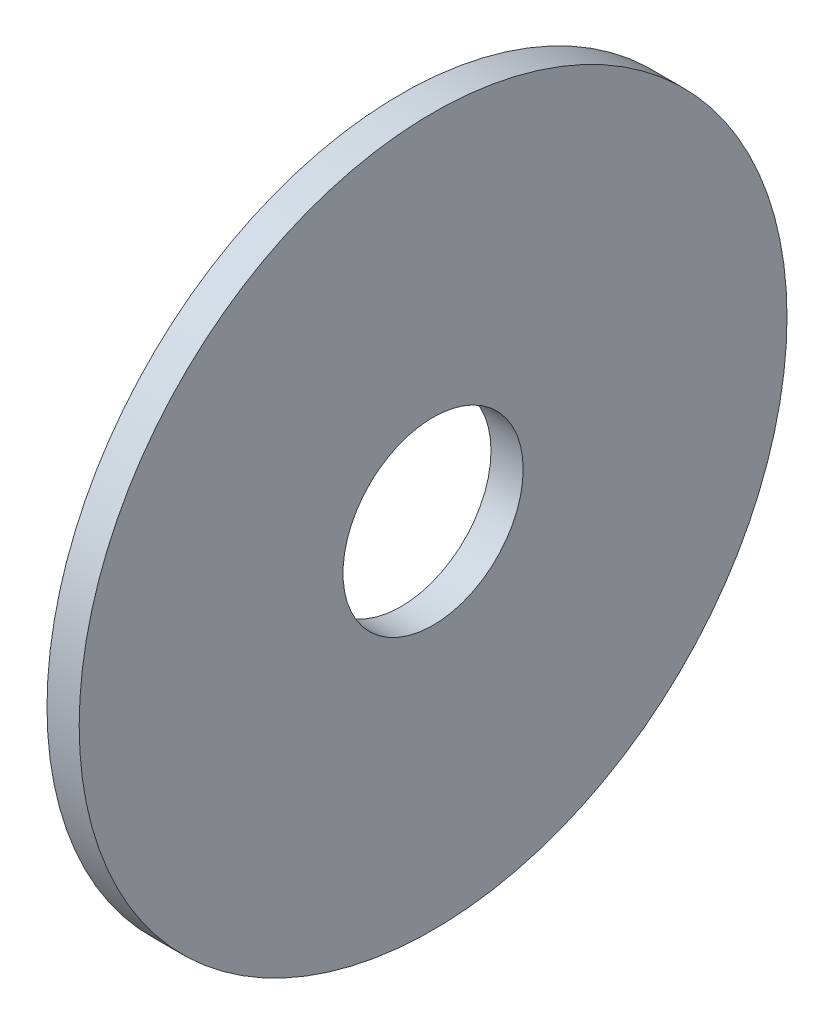
from build123d import *

# Parameters (mm, degrees)
SKETCH_1_R      = 55
SKETCH_1_R_2    = 14
EXTRUDE_1_DEPTH = 5


with BuildPart() as part:
    # Эскиз1 → Бобышка-Вытянуть1 (new body)
    with BuildSketch(Plane(origin=(0, 0, 0), x_dir=(0, 0, -1), z_dir=(1, 0, 0))):
        Circle(SKETCH_1_R)
        Circle(SKETCH_1_R_2, mode=Mode.SUBTRACT)
    extrude(amount=EXTRUDE_1_DEPTH)


solid = part.part
